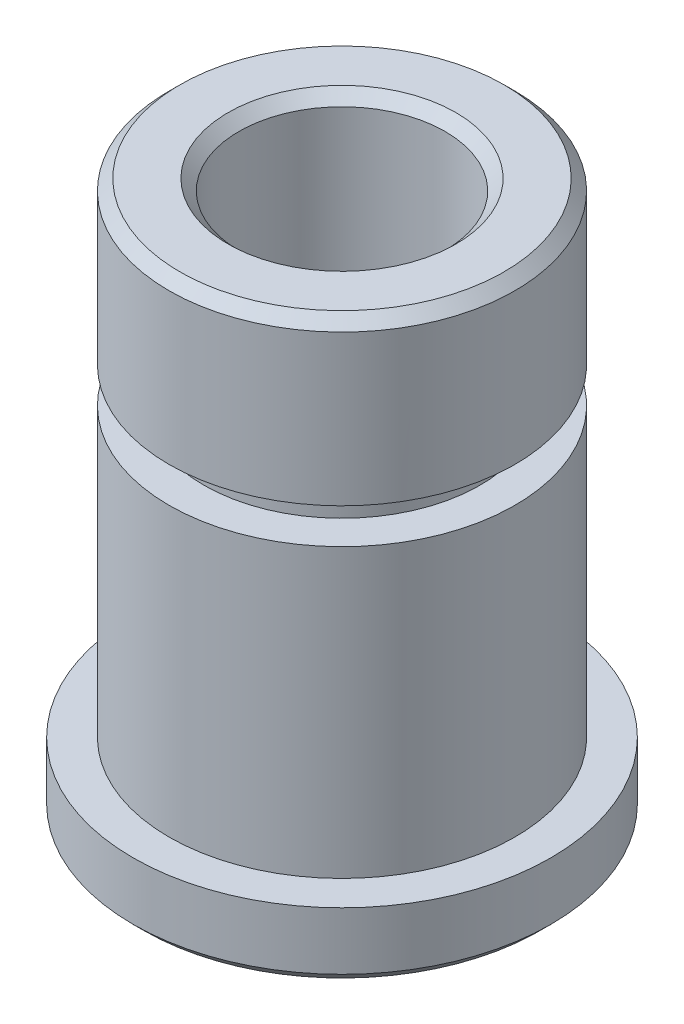
from build123d import *

# Parameters (mm, degrees)
CHAMFER1_SIZE = 0.25


with BuildPart() as part:
    # Sketch2 → Revolve1 (revolve)
    with BuildSketch(Plane(origin=(0, 0, 0), x_dir=(0, 0, -1), z_dir=(1, 0, 0))):
        Polygon((2.36855, 12.7), (3.9751, 12.7), (3.9751, 8.9916), (3.175, 8.9916), (3.175, 8.1788), (3.9751, 8.1788), (3.9751, 1.5748), (4.8006, 1.5748), (4.8006, 0), (2.36855, 0), align=None)
    revolve(axis=Axis((0, -1.359924362, 0), (0, -1, 0)))

    # Chamfer1
    chamfer1_edges = [part.edges().sort_by_distance(p)[0] for p in [
        (0, 0, 4.8006),
        (0, 0, 2.36855),
        (0, 12.7, 2.36855),
        (0, 12.7, 3.9751),
    ]]
    chamfer(chamfer1_edges, length=CHAMFER1_SIZE)


solid = part.part
